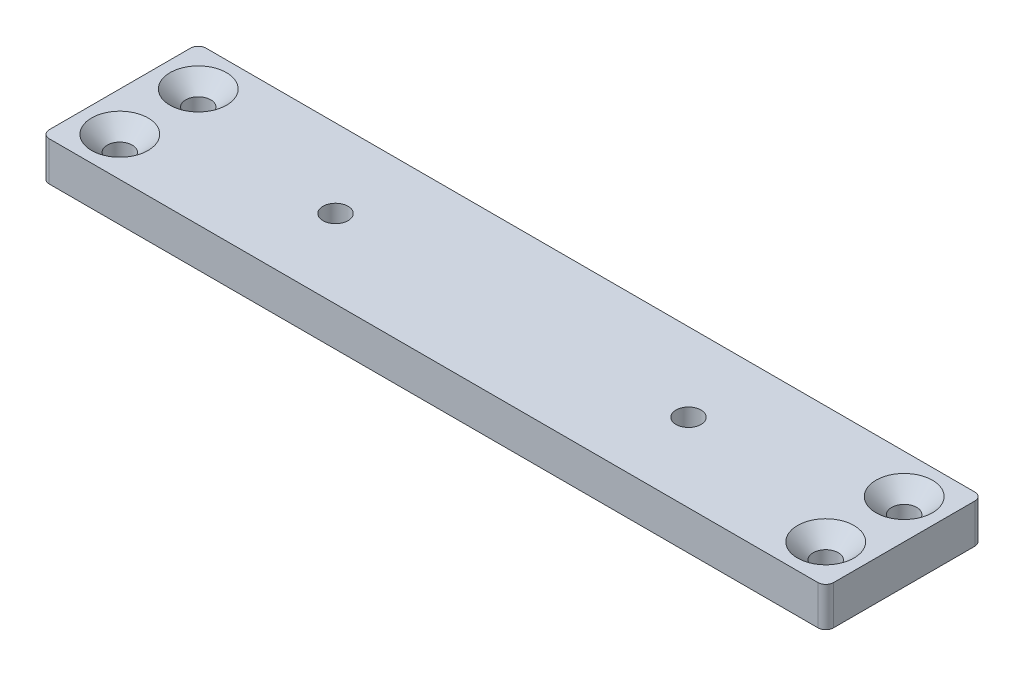
from build123d import *

# Parameters (mm, degrees)
ESQUISSE1_W                     = 100
ESQUISSE1_H                     = 20
BOSS_EXTRU_1_DEPTH              = 5
DIAM_TRE_DU_PER_AGE_3_2_3_2_1_D = 3.2
DIAM_TRE_DU_PER_AGE_3_2_3_2_2_D = 3.2
CONG_1_R                        = 1
CHANFREIN1_SIZE                 = 2
CHANFREIN2_SIZE                 = 2


with BuildPart() as part:
    # Esquisse1 → Boss.-Extru.1 (new body)
    with BuildSketch(Plane(origin=(0, 5, 0), x_dir=(1, 0, 0), z_dir=(0, 1, 0))):
        with Locations((0, -10)):
            Rectangle(ESQUISSE1_W, ESQUISSE1_H)
    extrude(amount=-BOSS_EXTRU_1_DEPTH)

    # Diamètre du perçage Ø3.2 (3.2)1 (through all)
    with Locations(Plane(origin=(0, 5, 0), x_dir=(1, 0, 0), z_dir=(0, 1, 0))):
        with Locations((22.5, -10), (-22.5, -10)):
            Hole(DIAM_TRE_DU_PER_AGE_3_2_3_2_1_D / 2)

    # Diamètre du perçage Ø3.2 (3.2)2 (through all)
    with Locations(Plane(origin=(0, 0, 0), x_dir=(-1, 0, 0), z_dir=(0, -1, 0))):
        with Locations((45, -15), (45, -5), (-45, -5), (-45, -15)):
            Hole(DIAM_TRE_DU_PER_AGE_3_2_3_2_2_D / 2)

    # Congé1
    cong_1_edges = [part.edges().sort_by_distance(p)[0] for p in [
        (-50, 2.5, 20),
        (-50, 2.5, 0),
        (50, 2.5, 0),
        (50, 2.5, 20),
    ]]
    fillet(cong_1_edges, radius=CONG_1_R)

    # Chanfrein1
    chanfrein1_edges = [part.edges().sort_by_distance(p)[0] for p in [
        (43.4, 5, 15),
        (43.4, 5, 5),
        (-46.6, 5, 5),
        (-46.6, 5, 15),
    ]]
    chamfer(chanfrein1_edges, length=CHANFREIN1_SIZE)

    # Chanfrein2
    chanfrein2_edges = [part.edges().sort_by_distance(p)[0] for p in [
        (-20.9, 0, 10),
        (24.1, 0, 10),
    ]]
    chamfer(chanfrein2_edges, length=CHANFREIN2_SIZE)


solid = part.part
